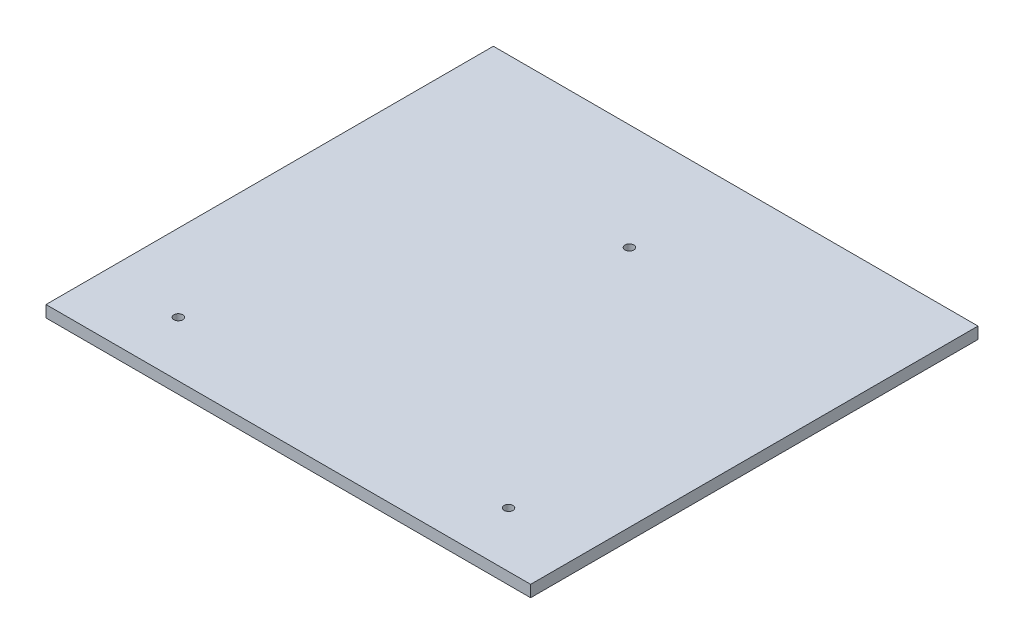
from build123d import *

# Parameters (mm, degrees)
SKETCH1_W           = 660.4
SKETCH1_H           = 609.6
BOSS_EXTRUDE1_DEPTH = 15.875
SKETCH5_R           = 5.9944
CUT_EXTRUDE2_DEPTH  = 16.875


with BuildPart() as part:
    # Sketch1 → Boss-Extrude1 (new body)
    with BuildSketch(Plane(origin=(0, 0, 0), x_dir=(1, 0, 0), z_dir=(0, 1, 0))):
        with Locations((330.2, 304.8)):
            Rectangle(SKETCH1_W, SKETCH1_H)
    extrude(amount=BOSS_EXTRUDE1_DEPTH)

    # Sketch5 → Cut-Extrude2 (cut, through all)
    with BuildSketch(Plane(origin=(0, 15.875, 0), x_dir=(1, 0, 0), z_dir=(0, 1, 0))):
        with Locations((105.2, 75.116646637)):
            Circle(SKETCH5_R)
        with Locations((555.2, 75.116646637)):
            Circle(SKETCH5_R)
        with Locations((330.2, 464.82807834)):
            Circle(SKETCH5_R)
    extrude(amount=-CUT_EXTRUDE2_DEPTH, mode=Mode.SUBTRACT)


solid = part.part
